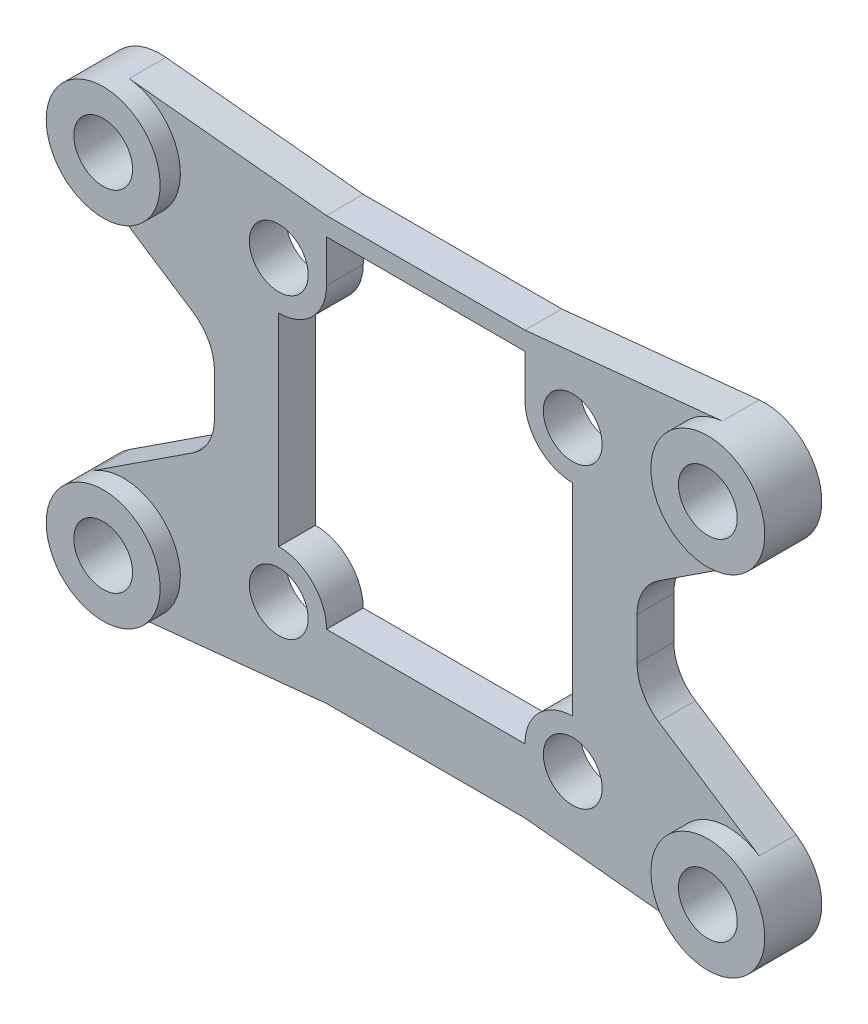
from build123d import *

# Parameters (mm, degrees)
SKETCH1_W             = 23
SKETCH1_H             = 23
BOSS_EXTRUDE1_DEPTH   = 2
FILLET1_R             = 2
SKETCH2_R             = 1.6
CUT_EXTRUDE1_DEPTH    = 2
SKETCH3_W             = 10.8
SKETCH3_H             = 2.3
CUT_EXTRUDE2_DEPTH    = 2
SKETCH5_R             = 1.6
BOSS_EXTRUDE2_DEPTH   = 2
BOSS_EXTRUDE2_2_DEPTH = 2
BOSS_EXTRUDE2_3_DEPTH = 2
BOSS_EXTRUDE2_4_DEPTH = 2
BOSS_EXTRUDE3_START   = 2
SKETCH6_R             = 3.1
SKETCH6_R_2           = 1.6
BOSS_EXTRUDE3_DEPTH   = 1.1


with BuildPart() as part:
    # Sketch1 → Boss-Extrude1 (new body)
    with BuildSketch(Plane.XY):
        with Locations((11.5, 11.5)):
            Rectangle(SKETCH1_W, SKETCH1_H)
    extrude(amount=BOSS_EXTRUDE1_DEPTH)

    # Fillet1
    fillet1_edges = [part.edges().sort_by_distance(p)[0] for p in [
        (0, 23, 1),
        (23, 23, 1),
        (23, 0, 1),
        (0, 0, 1),
    ]]
    fillet(fillet1_edges, radius=FILLET1_R)

    # Sketch2 → Cut-Extrude1 (cut)
    with BuildSketch(Plane.XY):
        with Locations((3.5, 19.7)):
            Circle(SKETCH2_R)
        with Locations((19.5, 19.7)):
            Circle(SKETCH2_R)
        with Locations((19.5, 3.5)):
            Circle(SKETCH2_R)
        with Locations((3.5, 3.5)):
            Circle(SKETCH2_R)
        with BuildLine():
            Line((3.5, 17.1), (3.5, 6.1))
            ThreePointArc((3.5, 6.1), (5.338477631, 5.338477631), (6.1, 3.5))
            Line((6.1, 3.5), (16.9, 3.5))
            ThreePointArc((16.9, 3.5), (17.661522369, 5.338477631), (19.5, 6.1))
            Line((19.5, 6.1), (19.5, 17.1))
            ThreePointArc((19.5, 17.1), (17.661522369, 17.861522369), (16.9, 19.7))
            Line((16.9, 19.7), (6.1, 19.7))
            ThreePointArc((6.1, 19.7), (5.338477631, 17.861522369), (3.5, 17.1))
        make_face()
    extrude(amount=CUT_EXTRUDE1_DEPTH, mode=Mode.SUBTRACT)

    # Sketch3 → Cut-Extrude2 (cut)
    with BuildSketch(Plane.XY):
        with Locations((11.5, 20.85)):
            Rectangle(SKETCH3_W, SKETCH3_H)
    extrude(amount=CUT_EXTRUDE2_DEPTH, mode=Mode.SUBTRACT)


with BuildPart() as body_2:
    # Sketch5 → Boss-Extrude2 (new body)
    with BuildSketch(Plane.XY):
        with BuildLine():
            Line((16.9, 23), (21.776453683, 21.561960094))
            Line((21.776453683, 21.561960094), (23, 12.648059803))
            ThreePointArc((23, 12.648059803), (23.313519219, 13.886650017), (24.17856315, 14.826915413))
            Line((24.17856315, 14.826915413), (29.65108056, 18.405475842))
            ThreePointArc((29.65108056, 18.405475842), (30.877170115, 22.033391556), (27.643175365, 24.084329386))
            Line((27.643175365, 24.084329386), (16.9, 23))
        make_face()
        with Locations((27.954482672, 21)):
            Circle(SKETCH5_R, mode=Mode.SUBTRACT)
    extrude(amount=BOSS_EXTRUDE2_DEPTH)


with BuildPart() as body_3:
    # Sketch5 → Boss-Extrude2 2 (new body)
    with BuildSketch(Plane.XY):
        with BuildLine():
            Line((-4.643175365, 24.084329386), (6.1, 23))
            Line((6.1, 23), (1.223546317, 21.561960094))
            Line((1.223546317, 21.561960094), (0, 12.648059803))
            ThreePointArc((0, 12.648059803), (-0.313519219, 13.886650017), (-1.17856315, 14.826915413))
            Line((-1.17856315, 14.826915413), (-6.65108056, 18.405475842))
            ThreePointArc((-6.65108056, 18.405475842), (-7.877170115, 22.033391556), (-4.643175365, 24.084329386))
        make_face()
        with Locations((-4.954482672, 21)):
            Circle(SKETCH5_R, mode=Mode.SUBTRACT)
    extrude(amount=BOSS_EXTRUDE2_2_DEPTH)


with BuildPart() as body_4:
    # Sketch5 → Boss-Extrude2 3 (new body)
    with BuildSketch(Plane.XY):
        with BuildLine():
            Line((16.9, 0), (21.776453683, 1.438039906))
            Line((21.776453683, 1.438039906), (23, 10.351940197))
            ThreePointArc((23, 10.351940197), (23.313519219, 9.113349983), (24.17856315, 8.173084587))
            Line((24.17856315, 8.173084587), (29.65108056, 4.594524158))
            ThreePointArc((29.65108056, 4.594524158), (30.877170115, 0.966608444), (27.643175365, -1.084329386))
            Line((27.643175365, -1.084329386), (16.9, 0))
        make_face()
        with Locations((27.954482672, 2)):
            Circle(SKETCH5_R, mode=Mode.SUBTRACT)
    extrude(amount=BOSS_EXTRUDE2_3_DEPTH)


with BuildPart() as body_5:
    # Sketch5 → Boss-Extrude2 4 (new body)
    with BuildSketch(Plane.XY):
        with BuildLine():
            Line((6.1, 0), (1.223546317, 1.438039906))
            Line((1.223546317, 1.438039906), (0, 10.351940197))
            ThreePointArc((0, 10.351940197), (-0.313519219, 9.113349983), (-1.17856315, 8.173084587))
            Line((-1.17856315, 8.173084587), (-6.65108056, 4.594524158))
            ThreePointArc((-6.65108056, 4.594524158), (-7.877170115, 0.966608444), (-4.643175365, -1.084329386))
            Line((-4.643175365, -1.084329386), (6.1, 0))
        make_face()
        with Locations((-4.954482672, 2)):
            Circle(SKETCH5_R, mode=Mode.SUBTRACT)
    extrude(amount=BOSS_EXTRUDE2_4_DEPTH)

    # Combine1: union part, body 3, body 2, body 4
    add(part.part)
    add(body_3.part)
    add(body_2.part)
    add(body_4.part)

    # Sketch6 → Boss-Extrude3 (add)
    with BuildSketch(Plane.XY.offset(BOSS_EXTRUDE3_START)):
        with Locations((-4.954482672, 21)):
            Circle(SKETCH6_R)
        with Locations((-4.954482672, 21)):
            Circle(SKETCH6_R_2, mode=Mode.SUBTRACT)
        with Locations((-4.954482672, 2)):
            Circle(SKETCH6_R)
        with Locations((-4.954482672, 2)):
            Circle(SKETCH6_R_2, mode=Mode.SUBTRACT)
        with Locations((27.954482672, 2)):
            Circle(SKETCH6_R)
        with Locations((27.954482672, 2)):
            Circle(SKETCH6_R_2, mode=Mode.SUBTRACT)
        with Locations((27.954482672, 21)):
            Circle(SKETCH6_R)
        with Locations((27.954482672, 21)):
            Circle(SKETCH6_R_2, mode=Mode.SUBTRACT)
    extrude(amount=BOSS_EXTRUDE3_DEPTH)


solid = body_5.part
